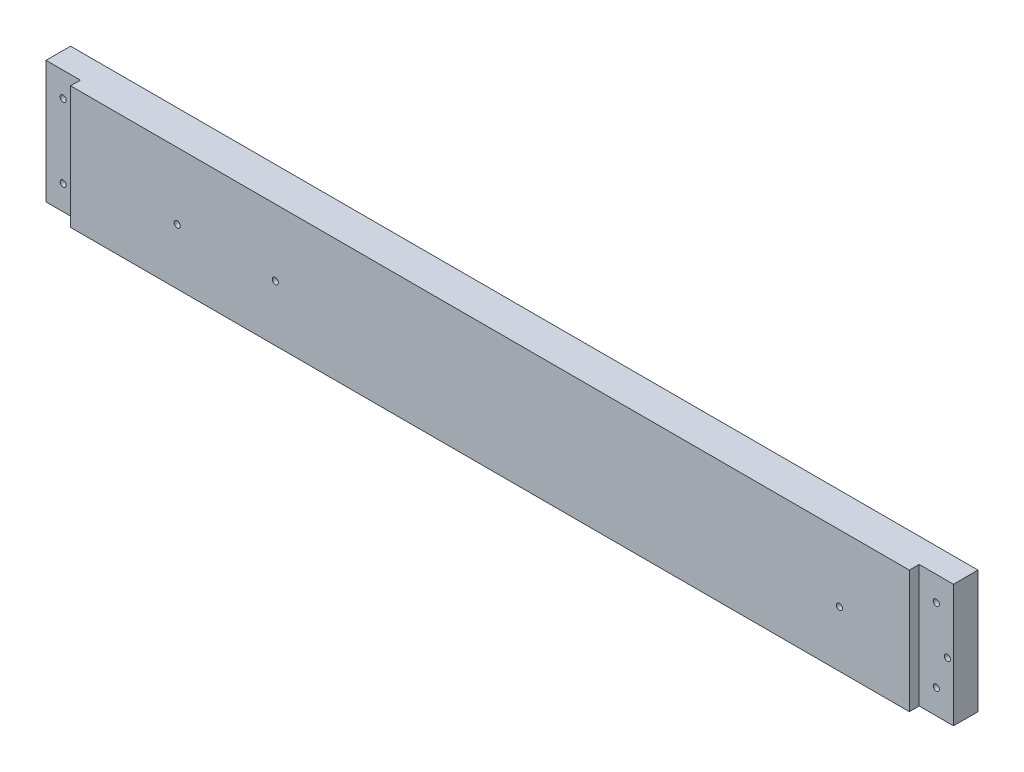
from build123d import *

# Parameters (mm, degrees)
SKETCH2_W          = 469.9
SKETCH2_H          = 63.5
EXTRUDE1_DEPTH     = 17.78
SKETCH3_W          = 17.78
SKETCH3_H          = 63.5
CUT_EXTRUDE1_DEPTH = 5.08
SKETCH4_R          = 1.5875
CUT_EXTRUDE2_DEPTH = 17.78
SKETCH5_R          = 1.5875
CUT_EXTRUDE3_DEPTH = 17.78


with BuildPart() as part:
    # Sketch2 → Extrude1 (new body)
    with BuildSketch(Plane.XY):
        with Locations((11073.341666666, -5688.0125)):
            Rectangle(SKETCH2_W, SKETCH2_H)
    extrude(amount=-EXTRUDE1_DEPTH)

    # Sketch3 → Cut-Extrude1 (cut)
    with BuildSketch(Plane.XY):
        with Locations((11299.401666666, -5688.0125)):
            Rectangle(SKETCH3_W, SKETCH3_H)
        with Locations((10847.281666666, -5688.0125)):
            Rectangle(SKETCH3_W, SKETCH3_H)
    extrude(amount=-CUT_EXTRUDE1_DEPTH, mode=Mode.SUBTRACT)

    # Sketch4 → Cut-Extrude2 (cut)
    with BuildSketch(Plane.XY):
        with Locations((10847.281666666, -5668.9625)):
            Circle(SKETCH4_R)
        with Locations((10847.281666666, -5707.0625)):
            Circle(SKETCH4_R)
        with Locations((11299.401666666, -5707.0625)):
            Circle(SKETCH4_R)
        with Locations((11299.401666666, -5668.9625)):
            Circle(SKETCH4_R)
    extrude(amount=-CUT_EXTRUDE2_DEPTH, mode=Mode.SUBTRACT)

    # Sketch5 → Cut-Extrude3 (cut)
    with BuildSketch(Plane(origin=(0, 0, -17.78), x_dir=(-1, 0, 0), z_dir=(0, 0, -1))):
        with Locations((-10911.416666665, -5690.78745)):
            Circle(SKETCH5_R)
        with Locations((-10962.216666665, -5690.78745)):
            Circle(SKETCH5_R)
        with Locations((-11254.316666665, -5690.78745)):
            Circle(SKETCH5_R)
        with Locations((-11305.116666665, -5690.78745)):
            Circle(SKETCH5_R)
    extrude(amount=-CUT_EXTRUDE3_DEPTH, mode=Mode.SUBTRACT)


solid = part.part
